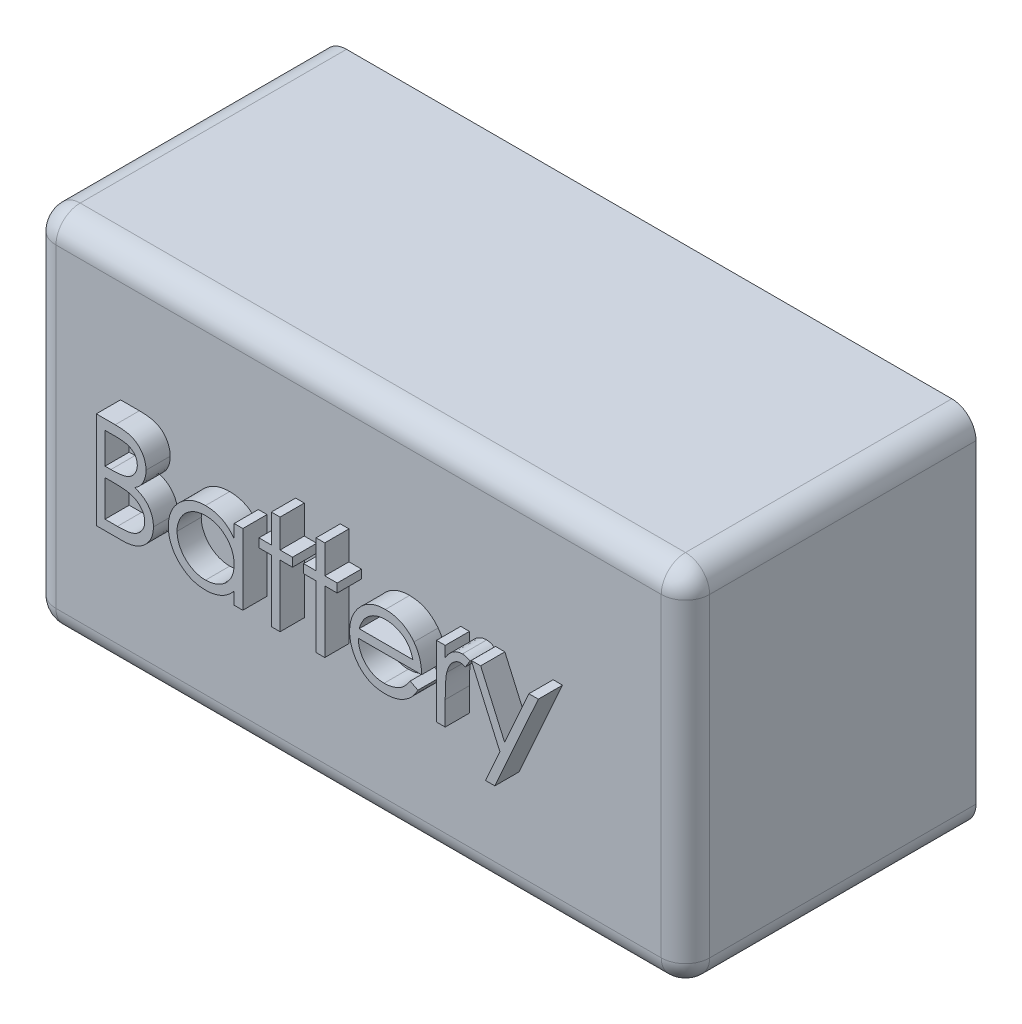
from build123d import *

# Parameters (mm, degrees)
SKETCH1_W           = 135
SKETCH1_H           = 75
BOSS_EXTRUDE1_DEPTH = 60
FILLET2_R           = 5
BOSS_EXTRUDE2_DEPTH = 5
FILLET4_R           = 5
FILLET5_R           = 5


with BuildPart() as part:
    # Sketch1 → Boss-Extrude1 (new body)
    with BuildSketch(Plane.XY):
        Rectangle(SKETCH1_W, SKETCH1_H)
    extrude(amount=BOSS_EXTRUDE1_DEPTH)

    # Fillet2
    fillet2_edges = [part.edges().sort_by_distance(p)[0] for p in [
        (67.5, 0, 60),
        (0, 37.5, 60),
        (67.5, 37.5, 30),
    ]]
    fillet(fillet2_edges, radius=FILLET2_R)

    # Sketch2 → Boss-Extrude2 (add)
    with BuildSketch(Plane.XY.offset(60)):
        with BuildLine():
            Line((-49.168272795, 11.469638403), (-45.266029205, 11.469638403))
            add(Edge.make_bspline(
                [(-45.266029205, 11.469638403), (-45.075009329, 11.468634115), (-44.70476527, 11.466687555), (-44.16636846, 11.436498234), (-43.662089542, 11.395334406), (-43.191782271, 11.330019591), (-42.755663972, 11.251209436), (-42.352420331, 11.155770487), (-41.983333632, 11.041332695), (-41.542689424, 10.859353945), (-41.040285648, 10.58893584), (-40.496294832, 10.189344039), (-40.03112775, 9.700587107), (-39.63006308, 9.149257647), (-39.311199539, 8.542767523), (-39.08051784, 7.895572159), (-38.934472838, 7.216019348), (-38.919453214, 6.749486903), (-38.911862538, 6.513708916)],
                knots=[0, 0, 0, 0, 0.000572973, 0.001110564, 0.001617291, 0.002090404, 0.002534393, 0.002946411, 0.003332879, 0.00369223, 0.004375214, 0.005039481, 0.005708156, 0.00639094, 0.007079111, 0.007755826, 0.008447278, 0.009153782, 0.009153782, 0.009153782, 0.009153782], degree=3))
            add(Edge.make_bspline(
                [(-38.911862538, 6.513708916), (-38.918109501, 6.292837169), (-38.930385371, 5.858803358), (-39.047772567, 5.223979876), (-39.231547816, 4.619687197), (-39.487006382, 4.048130709), (-39.819017789, 3.522224348), (-40.212493896, 3.037725685), (-40.687218481, 2.615148216), (-41.042894138, 2.378903059), (-41.223561256, 2.258901224)],
                knots=[0, 0, 0, 0, 0.00066204, 0.001300972, 0.001929557, 0.00255358, 0.003172762, 0.003790386, 0.004420221, 0.005070421, 0.005070421, 0.005070421, 0.005070421], degree=3))
            add(Edge.make_bspline(
                [(-41.223561256, 2.258901224), (-40.996358813, 2.171672658), (-40.561664256, 2.004782804), (-39.963458471, 1.70972301), (-39.448059357, 1.388796665), (-39.011504237, 1.03832895), (-38.638146209, 0.660564317), (-38.3121294, 0.249963664), (-38.033950119, -0.198829238), (-37.795590555, -0.681135154), (-37.609597664, -1.192029259), (-37.470306782, -1.726719408), (-37.390492787, -2.283288295), (-37.379134837, -2.662061892), (-37.373401, -2.853278264)],
                knots=[0, 0, 0, 0, 0.000729838, 0.00139636, 0.001997709, 0.002547697, 0.003071803, 0.003588008, 0.004117158, 0.004652894, 0.005199193, 0.005745301, 0.006307927, 0.006881529, 0.006881529, 0.006881529, 0.006881529], degree=3))
            add(Edge.make_bspline(
                [(-37.373401, -2.853278264), (-37.378982977, -3.048517533), (-37.389965674, -3.432656265), (-37.470994084, -3.99697132), (-37.608188981, -4.536256729), (-37.79716696, -5.05400063), (-38.043808758, -5.549201398), (-38.343968554, -6.02242005), (-38.701863203, -6.468901939), (-39.102222455, -6.893608357), (-39.555149, -7.275481427), (-40.043810457, -7.61557118), (-40.574360856, -7.895262963), (-41.138086536, -8.130211657), (-41.7413112, -8.309681363), (-42.381326099, -8.435238928), (-43.057579252, -8.519839139), (-43.521634973, -8.526794596), (-43.759618948, -8.530361597)],
                knots=[0, 0, 0, 0, 0.000585608, 0.0011522, 0.001706071, 0.002252369, 0.002802431, 0.003362598, 0.00393011, 0.004516704, 0.005110748, 0.005704183, 0.006299253, 0.00690638, 0.007533802, 0.008183594, 0.008861424, 0.00957497, 0.00957497, 0.00957497, 0.00957497], degree=3))
            Line((-43.759618948, -8.530361597), (-49.168272795, -8.530361597))
            Line((-49.168272795, -8.530361597), (-49.168272795, 11.469638403))
        make_face()
        with BuildLine():
            Line((-47.373401, 9.418356352), (-47.373401, 3.008099941))
            Line((-47.373401, 3.008099941), (-46.167471512, 3.008099941))
            add(Edge.make_bspline(
                [(-46.167471512, 3.008099941), (-45.991192682, 3.010385216), (-45.650586058, 3.014800832), (-45.157329506, 3.0274495), (-44.699472259, 3.062866891), (-44.277804641, 3.098274103), (-43.892990676, 3.155843176), (-43.545882896, 3.224369592), (-43.23103377, 3.296843336), (-42.867950653, 3.420097546), (-42.456105233, 3.60225569), (-42.017058924, 3.884951897), (-41.630004812, 4.221662486), (-41.303163739, 4.610182268), (-41.035669622, 5.037989044), (-40.849876964, 5.498256932), (-40.723892483, 5.97951483), (-40.712512304, 6.309904846), (-40.706734333, 6.477651224)],
                knots=[0, 0, 0, 0, 0.000528907, 0.001021956, 0.00147981, 0.001906375, 0.002291095, 0.002646244, 0.002967882, 0.003259278, 0.003795434, 0.00431443, 0.004819842, 0.005328719, 0.005832396, 0.006326421, 0.006813245, 0.007315343, 0.007315343, 0.007315343, 0.007315343], degree=3))
            add(Edge.make_bspline(
                [(-40.706734333, 6.477651224), (-40.709741077, 6.588655632), (-40.715639133, 6.806402901), (-40.76394372, 7.123827782), (-40.846044145, 7.422363511), (-40.951497249, 7.706101284), (-41.098861185, 7.966169), (-41.272366689, 8.211558689), (-41.481999205, 8.433913652), (-41.720612421, 8.641739357), (-41.994947408, 8.825993801), (-42.304840504, 8.987369591), (-42.654484373, 9.117316886), (-43.037986402, 9.231123472), (-43.461249759, 9.311056579), (-43.919390064, 9.377647366), (-44.416159887, 9.411548749), (-44.759846187, 9.416036537), (-44.937503564, 9.418356352)],
                knots=[0, 0, 0, 0, 0.000332918, 0.000653055, 0.000960167, 0.001260754, 0.001558444, 0.001854187, 0.002160356, 0.002472805, 0.002801721, 0.003149357, 0.003518403, 0.003919044, 0.004348048, 0.004809256, 0.005307357, 0.005840345, 0.005840345, 0.005840345, 0.005840345], degree=3))
            Line((-44.937503564, 9.418356352), (-47.373401, 9.418356352))
        make_face(mode=Mode.SUBTRACT)
        with BuildLine():
            Line((-47.373401, 0.95681789), (-47.373401, -6.479079546))
            Line((-47.373401, -6.479079546), (-44.817311256, -6.479079546))
            add(Edge.make_bspline(
                [(-44.817311256, -6.479079546), (-44.634345965, -6.476886703), (-44.281704488, -6.472660289), (-43.772554601, -6.458862834), (-43.300651151, -6.427478402), (-42.868147518, -6.378073547), (-42.470373503, -6.324482408), (-42.112100914, -6.252417946), (-41.790425523, -6.169852457), (-41.417429479, -6.042228616), (-40.997409432, -5.843963068), (-40.544775967, -5.545024631), (-40.142340434, -5.188891444), (-39.800596096, -4.776714792), (-39.520521876, -4.328535781), (-39.316776418, -3.853419495), (-39.19111438, -3.359216481), (-39.175901984, -3.022263838), (-39.168272795, -2.853278264)],
                knots=[0, 0, 0, 0, 0.000548937, 0.001058003, 0.001527848, 0.001967185, 0.002363799, 0.002731517, 0.003062888, 0.003359363, 0.003913147, 0.004450962, 0.004981641, 0.005519232, 0.006051783, 0.006561543, 0.007064886, 0.007571281, 0.007571281, 0.007571281, 0.007571281], degree=3))
            add(Edge.make_bspline(
                [(-39.168272795, -2.853278264), (-39.169850534, -2.747602032), (-39.172980563, -2.537954136), (-39.220184077, -2.229863741), (-39.288834761, -1.931430179), (-39.377585812, -1.641843091), (-39.506839909, -1.366338083), (-39.657734452, -1.099466314), (-39.834656748, -0.840875003), (-40.110337695, -0.513947841), (-40.511320464, -0.137279195), (-41.081073467, 0.231506532), (-41.728915169, 0.528922572), (-42.198786557, 0.655205294), (-42.441509974, 0.720439685)],
                knots=[0, 0, 0, 0, 0.000316735, 0.00062836, 0.000932557, 0.001235379, 0.00153479, 0.001843387, 0.002154549, 0.002473103, 0.003125078, 0.003796244, 0.004500837, 0.005253744, 0.005253744, 0.005253744, 0.005253744], degree=3))
            add(Edge.make_bspline(
                [(-42.441509974, 0.720439685), (-42.538819093, 0.740183022), (-42.749805335, 0.782990649), (-43.093848652, 0.828177525), (-43.486625046, 0.86843501), (-43.929041487, 0.898213054), (-44.421657722, 0.928993303), (-44.965525829, 0.940963709), (-45.55842477, 0.955245196), (-45.969809755, 0.956280248), (-46.183497154, 0.95681789)],
                knots=[0, 0, 0, 0, 0.000297798, 0.000645687, 0.001040354, 0.001482223, 0.001975809, 0.002520917, 0.003113987, 0.003755025, 0.003755025, 0.003755025, 0.003755025], degree=3))
            Line((-46.183497154, 0.95681789), (-47.373401, 0.95681789))
        make_face(mode=Mode.SUBTRACT)
        with BuildLine():
            Line((-18.911862538, 6.085023018), (-18.911862538, -8.530361597))
            Line((-18.911862538, -8.530361597), (-20.706734333, -8.530361597))
            Line((-20.706734333, -8.530361597), (-20.706734333, -6.002316725))
            add(Edge.make_bspline(
                [(-20.706734333, -6.002316725), (-20.909127422, -6.231114405), (-21.304100081, -6.677615954), (-21.963763612, -7.260942654), (-22.663010343, -7.743104491), (-23.398446464, -8.132532581), (-24.169407854, -8.425058617), (-24.974185496, -8.632979527), (-25.813107672, -8.766658585), (-26.385978271, -8.780007281), (-26.676285615, -8.786771853)],
                knots=[0, 0, 0, 0, 0.000915787, 0.00178717, 0.002633992, 0.003458379, 0.004277589, 0.005101635, 0.005948733, 0.006819046, 0.006819046, 0.006819046, 0.006819046], degree=3))
            add(Edge.make_bspline(
                [(-26.676285615, -8.786771853), (-26.934388208, -8.779764012), (-27.443377951, -8.765944238), (-28.192115534, -8.658731075), (-28.912642674, -8.486556094), (-29.605640232, -8.247122439), (-30.26662392, -7.929517744), (-30.901253044, -7.549282041), (-31.506239856, -7.096477298), (-32.072362935, -6.578831422), (-32.593688652, -6.016574352), (-33.051181638, -5.416885513), (-33.432627809, -4.782358062), (-33.751599699, -4.121025754), (-33.997293095, -3.427797642), (-34.168571005, -2.705070968), (-34.275659272, -1.953700262), (-34.289473333, -1.442045845), (-34.296477923, -1.182605187)],
                knots=[0, 0, 0, 0, 0.000774077, 0.001526515, 0.002264065, 0.002993891, 0.003721471, 0.004460097, 0.005210099, 0.005984373, 0.006758399, 0.007507608, 0.008242804, 0.008975725, 0.009706881, 0.010444431, 0.011200836, 0.011978916, 0.011978916, 0.011978916, 0.011978916], degree=3))
            add(Edge.make_bspline(
                [(-34.296477923, -1.182605187), (-34.289318086, -0.928526881), (-34.275163476, -0.426227776), (-34.169716505, 0.312507641), (-33.992396456, 1.02404056), (-33.743551612, 1.706080235), (-33.424454726, 2.35945195), (-33.036294229, 2.984617808), (-32.579042088, 3.583300079), (-32.051885477, 4.141421375), (-31.480829647, 4.656967742), (-30.869922613, 5.10501943), (-30.234361006, 5.491972852), (-29.56428666, 5.798564145), (-28.86961749, 6.046616171), (-28.144169228, 6.218233132), (-27.390960207, 6.319360682), (-26.879585967, 6.334005048), (-26.620195871, 6.341433275)],
                knots=[0, 0, 0, 0, 0.000762071, 0.001506574, 0.002233404, 0.002958376, 0.003680475, 0.004410928, 0.005162565, 0.005936384, 0.006710948, 0.007467386, 0.008206012, 0.008939141, 0.009674074, 0.01041552, 0.011171384, 0.011949464, 0.011949464, 0.011949464, 0.011949464], degree=3))
            add(Edge.make_bspline(
                [(-26.620195871, 6.341433275), (-26.321910963, 6.333217552), (-25.736988334, 6.317106906), (-24.88139971, 6.183034179), (-24.072002693, 5.956528652), (-23.302549253, 5.648428664), (-22.575802475, 5.239007355), (-21.898642565, 4.722550434), (-21.26398266, 4.10231508), (-20.896095279, 3.625912541), (-20.706734333, 3.380696095)],
                knots=[0, 0, 0, 0, 0.000894516, 0.001754103, 0.002590062, 0.003411415, 0.004234847, 0.005084215, 0.005959641, 0.006888195, 0.006888195, 0.006888195, 0.006888195], degree=3))
            Line((-20.706734333, 3.380696095), (-20.706734333, 6.085023018))
            Line((-20.706734333, 6.085023018), (-18.911862538, 6.085023018))
        make_face()
        with BuildLine():
            add(Edge.make_bspline(
                [(-26.59615741, 4.54656148), (-26.858525055, 4.537226407), (-27.376397055, 4.518800458), (-28.136648495, 4.374951915), (-28.864153718, 4.135611375), (-29.555274143, 3.808286226), (-30.199092524, 3.396693445), (-30.774484928, 2.898856969), (-31.286157507, 2.328359745), (-31.716490446, 1.687776257), (-32.067293285, 1.001044308), (-32.313962039, 0.283190376), (-32.476643453, -0.452838067), (-32.493263571, -0.952053414), (-32.501606128, -1.202637238)],
                knots=[0, 0, 0, 0, 0.000786727, 0.001552874, 0.002311779, 0.003078805, 0.003841171, 0.004596866, 0.005354459, 0.006133415, 0.006905655, 0.007660818, 0.008405709, 0.009156448, 0.009156448, 0.009156448, 0.009156448], degree=3))
            add(Edge.make_bspline(
                [(-32.501606128, -1.202637238), (-32.490949595, -1.451723565), (-32.469678298, -1.948919884), (-32.316817187, -2.685951751), (-32.060360768, -3.403974849), (-31.710406124, -4.096894812), (-31.27219684, -4.740232528), (-30.764261682, -5.321604657), (-30.181688646, -5.821545161), (-29.536388606, -6.240045582), (-28.847200203, -6.57811713), (-28.122434881, -6.813349356), (-27.375716948, -6.965222388), (-26.867989326, -6.982962256), (-26.612183051, -6.991900059)],
                knots=[0, 0, 0, 0, 0.00074701, 0.001491092, 0.002247583, 0.003028781, 0.003813302, 0.004576888, 0.005338233, 0.006108318, 0.006878811, 0.00763391, 0.008388999, 0.009155732, 0.009155732, 0.009155732, 0.009155732], degree=3))
            add(Edge.make_bspline(
                [(-26.612183051, -6.991900059), (-26.352488749, -6.98241455), (-25.835982541, -6.963548815), (-25.073475639, -6.819084442), (-24.333504423, -6.580405595), (-23.626148832, -6.249553442), (-22.967199511, -5.839511408), (-22.375783068, -5.359470888), (-21.87569182, -4.801166979), (-21.451734051, -4.187587247), (-21.119303098, -3.514947267), (-20.877154188, -2.798751892), (-20.733989013, -2.038976188), (-20.715944843, -1.519753748), (-20.706734333, -1.254720571)],
                knots=[0, 0, 0, 0, 0.000778729, 0.001548815, 0.002319151, 0.00310601, 0.003885296, 0.004642454, 0.005382773, 0.006126219, 0.006873369, 0.007625934, 0.008388143, 0.009182867, 0.009182867, 0.009182867, 0.009182867], degree=3))
            add(Edge.make_bspline(
                [(-20.706734333, -1.254720571), (-20.712218084, -1.052790111), (-20.72301184, -0.655327064), (-20.805472238, -0.071741249), (-20.936643246, 0.486737186), (-21.121478503, 1.020695409), (-21.364285843, 1.527181211), (-21.657130219, 2.009831269), (-22.00516136, 2.466135334), (-22.402776767, 2.889810026), (-22.838006496, 3.276246953), (-23.298546728, 3.621185471), (-23.789853853, 3.904549887), (-24.303665493, 4.139071438), (-24.840873118, 4.325695152), (-25.405848089, 4.450196259), (-25.992585157, 4.535683808), (-26.39284833, 4.542897412), (-26.59615741, 4.54656148)],
                knots=[0, 0, 0, 0, 0.000605618, 0.001192047, 0.001764417, 0.002324456, 0.002883576, 0.003446316, 0.00401524, 0.004601998, 0.005186577, 0.005759508, 0.006325037, 0.006884401, 0.007452012, 0.008027375, 0.008617773, 0.009227222, 0.009227222, 0.009227222, 0.009227222], degree=3))
        make_face(mode=Mode.SUBTRACT)
        Polygon((-13.014426641, 11.982458916), (-11.219554846, 11.982458916), (-11.219554846, 6.085023018), (-8.655452282, 6.085023018), (-8.655452282, 4.290151224), (-11.219554846, 4.290151224), (-11.219554846, -8.530361597), (-13.014426641, -8.530361597), (-13.014426641, 4.290151224), (-15.578529205, 4.290151224), (-15.578529205, 6.085023018), (-13.014426641, 6.085023018), align=None)
        Polygon((-3.78365741, 11.982458916), (-1.988785615, 11.982458916), (-1.988785615, 6.085023018), (0.575316949, 6.085023018), (0.575316949, 4.290151224), (-1.988785615, 4.290151224), (-1.988785615, -8.530361597), (-3.78365741, -8.530361597), (-3.78365741, 4.290151224), (-6.347759974, 4.290151224), (-6.347759974, 6.085023018), (-3.78365741, 6.085023018), align=None)
        with BuildLine():
            Line((15.647432334, -3.914976982), (17.241983616, -4.752316725))
            add(Edge.make_bspline(
                [(17.241983616, -4.752316725), (17.114917357, -4.97770719), (16.867696737, -5.416227777), (16.442549606, -6.018695551), (15.99688062, -6.560682499), (15.510572232, -7.027709095), (14.998174066, -7.434859866), (14.45684461, -7.791076007), (13.883765652, -8.094610409), (13.278910082, -8.35033914), (12.637198361, -8.546964821), (11.95707541, -8.685846083), (11.237238294, -8.771693332), (10.743831551, -8.781665565), (10.491182334, -8.786771853)],
                knots=[0, 0, 0, 0, 0.000775766, 0.001509333, 0.002209022, 0.002877697, 0.003527798, 0.004170074, 0.004818878, 0.005470692, 0.006137275, 0.006828726, 0.007550792, 0.008308523, 0.008308523, 0.008308523, 0.008308523], degree=3))
            add(Edge.make_bspline(
                [(10.491182334, -8.786771853), (10.210371033, -8.780216566), (9.662589538, -8.767429099), (8.865219555, -8.657186445), (8.114480021, -8.477344395), (7.410413145, -8.22611273), (6.75474313, -7.897956592), (6.146166817, -7.498188124), (5.581483812, -7.028860955), (5.078488331, -6.485909849), (4.625666144, -5.904870093), (4.22609003, -5.299407896), (3.892047567, -4.671046613), (3.620318365, -4.023786476), (3.400861994, -3.361707084), (3.247909401, -2.678784412), (3.159739413, -1.976866788), (3.146228295, -1.50202487), (3.139419513, -1.262733392)],
                knots=[0, 0, 0, 0, 0.000842118, 0.001642729, 0.00240942, 0.003154591, 0.003880238, 0.004603637, 0.005334617, 0.006077199, 0.006819326, 0.007542724, 0.008250681, 0.008950886, 0.009646446, 0.010340434, 0.011047075, 0.011764938, 0.011764938, 0.011764938, 0.011764938], degree=3))
            add(Edge.make_bspline(
                [(3.139419513, -1.262733392), (3.145471749, -1.038191504), (3.157466482, -0.593179134), (3.233070982, 0.06548112), (3.367061228, 0.705643706), (3.550925936, 1.327840552), (3.788361628, 1.931029889), (4.078831453, 2.515578824), (4.422787897, 3.080865337), (4.688346033, 3.437454673), (4.822111821, 3.6170743)],
                knots=[0, 0, 0, 0, 0.000673661, 0.001335107, 0.001985702, 0.002633465, 0.003279243, 0.003927849, 0.004589538, 0.005261134, 0.005261134, 0.005261134, 0.005261134], degree=3))
            add(Edge.make_bspline(
                [(4.822111821, 3.6170743), (5.00329858, 3.833467844), (5.35993256, 4.259400132), (5.963111734, 4.819047708), (6.616255713, 5.28786928), (7.31117929, 5.676481487), (8.055959142, 5.97175947), (8.840583662, 6.191802797), (9.673987012, 6.315105717), (10.243731131, 6.332521909), (10.535252846, 6.341433275)],
                knots=[0, 0, 0, 0, 0.000846121, 0.001665439, 0.002460457, 0.003253129, 0.004047692, 0.004858345, 0.005692958, 0.006567466, 0.006567466, 0.006567466, 0.006567466], degree=3))
            add(Edge.make_bspline(
                [(10.535252846, 6.341433275), (10.834953448, 6.333695853), (11.422897711, 6.318516794), (12.280224117, 6.177794889), (13.091428211, 5.954637434), (13.856185379, 5.639472917), (14.574573154, 5.232846907), (15.241922009, 4.729179241), (15.869644938, 4.143933028), (16.234836817, 3.693857546), (16.420669513, 3.464830711)],
                knots=[0, 0, 0, 0, 0.000898517, 0.001762686, 0.002598645, 0.003417806, 0.004237751, 0.005067881, 0.005920983, 0.006804875, 0.006804875, 0.006804875, 0.006804875], degree=3))
            add(Edge.make_bspline(
                [(16.420669513, 3.464830711), (16.547109161, 3.292238817), (16.799146835, 2.948203853), (17.11484455, 2.387225813), (17.388886807, 1.800308131), (17.607932299, 1.177963576), (17.785300877, 0.527565975), (17.913625555, -0.155534281), (17.988880519, -0.871133774), (18.003673075, -1.358714091), (18.011214385, -1.607284674)],
                knots=[0, 0, 0, 0, 0.000641339, 0.001278408, 0.001927311, 0.002582466, 0.003255018, 0.003948069, 0.004665261, 0.005411142, 0.005411142, 0.005411142, 0.005411142], degree=3))
            Line((18.011214385, -1.607284674), (4.934291308, -1.607284674))
            add(Edge.make_bspline(
                [(4.934291308, -1.607284674), (4.943089059, -1.799858755), (4.960389482, -2.17854792), (5.041047443, -2.73266668), (5.168183293, -3.26051435), (5.346863651, -3.758131732), (5.563245624, -4.232018175), (5.828306862, -4.678658386), (6.144532885, -5.096017987), (6.497251167, -5.487830202), (6.88986314, -5.836748837), (7.30290741, -6.149044701), (7.74229921, -6.410790968), (8.204573973, -6.623247481), (8.688984174, -6.789569287), (9.195682432, -6.903099691), (9.723671668, -6.979140302), (10.083590148, -6.987595531), (10.266823359, -6.991900059)],
                knots=[0, 0, 0, 0, 0.000578049, 0.00113671, 0.001676981, 0.002204125, 0.002720392, 0.003237778, 0.003758611, 0.004288988, 0.00481668, 0.005331905, 0.005840356, 0.006347669, 0.006855726, 0.007373731, 0.007903503, 0.008452907, 0.008452907, 0.008452907, 0.008452907], degree=3))
            add(Edge.make_bspline(
                [(10.266823359, -6.991900059), (10.445972774, -6.988425449), (10.801439579, -6.981531157), (11.330815907, -6.914491666), (11.851613207, -6.806090091), (12.361675968, -6.658147291), (12.85065223, -6.477708136), (13.303483945, -6.259977521), (13.71994232, -6.019121825), (14.109182129, -5.743637968), (14.486730663, -5.406448328), (14.861259156, -4.985672779), (15.262840033, -4.488029763), (15.514209134, -4.113483101), (15.647432334, -3.914976982)],
                knots=[0, 0, 0, 0, 0.000537233, 0.001065972, 0.001597921, 0.002131736, 0.002657859, 0.003159621, 0.003637191, 0.004099667, 0.004587759, 0.005152094, 0.005787802, 0.006504636, 0.006504636, 0.006504636, 0.006504636], degree=3))
        make_face()
        with BuildLine():
            add(Edge.make_bspline(
                [(16.21634259, 0.187587121), (16.150647593, 0.425660685), (16.02420587, 0.88387566), (15.759998073, 1.518395034), (15.462446412, 2.082325897), (15.110322233, 2.571352371), (14.711358086, 3.00565816), (14.250528471, 3.385192932), (13.733751937, 3.724721224), (13.163699704, 4.011306935), (12.560032361, 4.255248985), (11.927996978, 4.418821075), (11.283095333, 4.530875603), (10.846899411, 4.541310508), (10.627400282, 4.54656148)],
                knots=[0, 0, 0, 0, 0.000740243, 0.00142473, 0.002057515, 0.002649, 0.003227368, 0.003821898, 0.004435284, 0.005078535, 0.005733237, 0.006384361, 0.007033796, 0.007691628, 0.007691628, 0.007691628, 0.007691628], degree=3))
            add(Edge.make_bspline(
                [(10.627400282, 4.54656148), (10.448260634, 4.543066214), (10.094139211, 4.536156808), (9.572418821, 4.470613212), (9.07139197, 4.362271241), (8.587361755, 4.213900061), (8.126671079, 4.016136618), (7.679843832, 3.784232466), (7.258241567, 3.501137701), (6.994577022, 3.285372816), (6.861374641, 3.176369172)],
                knots=[0, 0, 0, 0, 0.000537233, 0.001061996, 0.001574347, 0.002073623, 0.002578129, 0.003076343, 0.003581929, 0.004098135, 0.004098135, 0.004098135, 0.004098135], degree=3))
            add(Edge.make_bspline(
                [(6.861374641, 3.176369172), (6.765984459, 3.09011594), (6.572937977, 2.91556042), (6.31499214, 2.614822097), (6.068018011, 2.290527456), (5.843254281, 1.930269601), (5.637096644, 1.538150864), (5.444182488, 1.117478662), (5.270545848, 0.665060775), (5.172853791, 0.349789694), (5.12259259, 0.187587121)],
                knots=[0, 0, 0, 0, 0.000385449, 0.000780055, 0.001186306, 0.001607589, 0.002052066, 0.002514611, 0.002995264, 0.003504598, 0.003504598, 0.003504598, 0.003504598], degree=3))
            Line((5.12259259, 0.187587121), (16.21634259, 0.187587121))
        make_face(mode=Mode.SUBTRACT)
        with BuildLine():
            Line((21.088137462, 6.085023018), (22.883009257, 6.085023018))
            Line((22.883009257, 6.085023018), (22.883009257, 3.933580711))
            add(Edge.make_bspline(
                [(22.883009257, 3.933580711), (23.01551645, 4.13389973), (23.268935426, 4.517008297), (23.690152166, 5.023690017), (24.121599773, 5.443204569), (24.5653437, 5.777510391), (25.024647128, 6.02787107), (25.48942971, 6.211259841), (25.967003823, 6.319701643), (26.287929104, 6.334179694), (26.448714385, 6.341433275)],
                knots=[0, 0, 0, 0, 0.000720129, 0.001377242, 0.001972271, 0.002521953, 0.003038345, 0.003536833, 0.004017018, 0.004499137, 0.004499137, 0.004499137, 0.004499137], degree=3))
            add(Edge.make_bspline(
                [(26.448714385, 6.341433275), (26.573436251, 6.334630266), (26.830059595, 6.320632632), (27.218531536, 6.222285063), (27.618779833, 6.065267791), (27.876736332, 5.917609376), (28.011214385, 5.840631993)],
                knots=[0, 0, 0, 0, 0.000373972, 0.000769472, 0.001195774, 0.001660051, 0.001660051, 0.001660051, 0.001660051], degree=3))
            Line((28.011214385, 5.840631993), (27.025637462, 4.286144813))
            add(Edge.make_bspline(
                [(27.025637462, 4.286144813), (26.939300198, 4.32466062), (26.775415544, 4.397770993), (26.535675165, 4.484296766), (26.314638955, 4.535244856), (26.173818622, 4.542963242), (26.108169513, 4.54656148)],
                knots=[0, 0, 0, 0, 0.000283551, 0.000538234, 0.00076377, 0.000960737, 0.000960737, 0.000960737, 0.000960737], degree=3))
            add(Edge.make_bspline(
                [(26.108169513, 4.54656148), (25.96413675, 4.536961266), (25.670351665, 4.517379614), (25.239011668, 4.363443569), (24.820456208, 4.114727911), (24.488046709, 3.838892987), (24.230662407, 3.572905573), (24.047003975, 3.340628986), (23.878531136, 3.080179663), (23.717558448, 2.796010042), (23.570893909, 2.483268064), (23.434010085, 2.145078273), (23.310245154, 1.781048966), (23.23967233, 1.527434565), (23.203522077, 1.397523018)],
                knots=[0, 0, 0, 0, 0.000431373, 0.000879877, 0.001357447, 0.001886839, 0.002170192, 0.002466774, 0.002773468, 0.003099959, 0.003445836, 0.003808897, 0.004194054, 0.004598543, 0.004598543, 0.004598543, 0.004598543], degree=3))
            add(Edge.make_bspline(
                [(23.203522077, 1.397523018), (23.176479829, 1.281653455), (23.116583305, 1.025011177), (23.058345946, 0.594448179), (23.000805844, 0.085741557), (22.960253739, -0.502524688), (22.922664927, -1.16888151), (22.901464457, -1.914344057), (22.883732225, -2.739677492), (22.883257557, -3.316673796), (22.883009257, -3.618502623)],
                knots=[0, 0, 0, 0, 0.000356773, 0.000790225, 0.001302121, 0.00189271, 0.002558751, 0.003304331, 0.004129807, 0.005035265, 0.005035265, 0.005035265, 0.005035265], degree=3))
            Line((22.883009257, -3.618502623), (22.883009257, -8.530361597))
            Line((22.883009257, -8.530361597), (21.088137462, -8.530361597))
            Line((21.088137462, -8.530361597), (21.088137462, 6.085023018))
        make_face()
        Polygon((28.267624641, 6.085023018), (30.202720795, 6.085023018), (35.150637462, -5.108887238), (40.174675923, 6.085023018), (42.113778488, 6.085023018), (33.139419513, -13.914976982), (31.200316949, -13.914976982), (34.17707977, -7.284368007), align=None)
    extrude(amount=BOSS_EXTRUDE2_DEPTH)

    # Fillet4
    fillet4_edges = [part.edges().sort_by_distance(p)[0] for p in [
        (-2.5, -37.5, 60),
        (67.5, -37.5, 27.5),
        (66.035533906, -37.5, 58.535533906),
    ]]
    fillet(fillet4_edges, radius=FILLET4_R)

    # Fillet5
    fillet5_edges = [part.edges().sort_by_distance(p)[0] for p in [
        (-67.5, 0, 60),
        (-67.5, 37.5, 27.5),
        (-67.5, 36.035533906, 58.535533906),
        (-67.5, -37.5, 27.5),
        (-67.5, -36.035533906, 58.535533906),
    ]]
    fillet(fillet5_edges, radius=FILLET5_R)


solid = part.part
